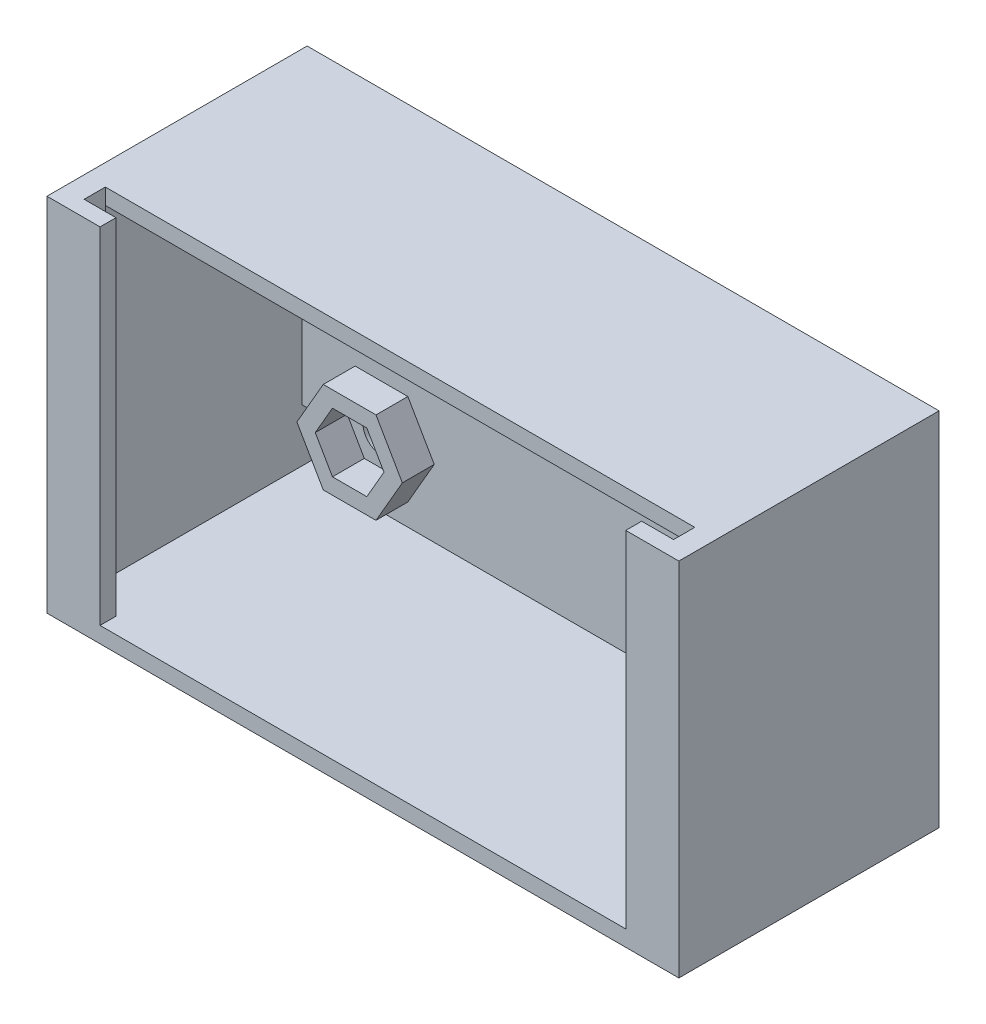
from build123d import *

# Parameters (mm, degrees)
CROQUIS1_W              = 59.5
CROQUIS1_H              = 34
CROQUIS1_W_2            = 56.5
CROQUIS1_H_2            = 31
EXTRUIR_L_MINA1_DEPTH   = 19
CROQUIS2_W              = 59.5
CROQUIS2_H              = 34
SALIENTE_EXTRUIR1_DEPTH = 2
SALIENTE_EXTRUIR3_DEPTH = 34
CROQUIS5_W              = 59.5
CROQUIS5_H              = 1.5
SALIENTE_EXTRUIR4_DEPTH = 3.5
CROQUIS6_W              = 5
CROQUIS6_H              = 5
CORTAR_EXTRUIR1_DEPTH   = 3.5
CROQUIS7_R              = 1.75
CORTAR_EXTRUIR2_DEPTH   = 3.5
EXTRUIR_L_MINA2_DEPTH   = 3


with BuildPart() as part:
    # Croquis1 → Extruir-Lámina1 (new body)
    with BuildSketch(Plane.XY):
        Rectangle(CROQUIS1_W, CROQUIS1_H)
        Rectangle(CROQUIS1_W_2, CROQUIS1_H_2, mode=Mode.SUBTRACT)
    extrude(amount=EXTRUIR_L_MINA1_DEPTH)

    # Croquis2 → Saliente-Extruir1 (add)
    with BuildSketch(Plane(origin=(0, 0, 0), x_dir=(-1, 0, 0), z_dir=(0, 0, -1))):
        Rectangle(CROQUIS2_W, CROQUIS2_H)
    extrude(amount=SALIENTE_EXTRUIR1_DEPTH)

    # Croquis4 → Saliente-Extruir3 (add)
    with BuildSketch(Plane(origin=(0, 17, 0), x_dir=(1, 0, 0), z_dir=(0, 1, 0))):
        Polygon((-29.75, -19), (-29.75, -22.5), (-24.75, -22.5), (-24.75, -21), (-27.75, -21), (-27.75, -19), align=None)
        Polygon((27.75, -21), (27.75, -19), (29.75, -19), (29.75, -22.5), (24.75, -22.5), (24.75, -21), align=None)
    extrude(amount=-SALIENTE_EXTRUIR3_DEPTH)

    # Croquis5 → Saliente-Extruir4 (add)
    with BuildSketch(Plane.XY.offset(19)):
        with Locations((0, -16.25)):
            Rectangle(CROQUIS5_W, CROQUIS5_H)
    extrude(amount=SALIENTE_EXTRUIR4_DEPTH)

    # Croquis6 → Cortar-Extruir1 (cut)
    with BuildSketch(Plane.XY):
        with Locations((-25.75, -13)):
            Rectangle(CROQUIS6_W, CROQUIS6_H)
    extrude(amount=-CORTAR_EXTRUIR1_DEPTH, mode=Mode.SUBTRACT)

    # Croquis7 → Cortar-Extruir2 (cut)
    with BuildSketch(Plane(origin=(0, 0, -2), x_dir=(-1, 0, 0), z_dir=(0, 0, -1))):
        with Locations((20.75, 12.11)):
            Circle(CROQUIS7_R)
        with Locations((20.75, -9.14)):
            Circle(CROQUIS7_R)
        with Locations((-24.25, -9.14)):
            Circle(CROQUIS7_R)
        with Locations((-24.25, 12.11)):
            Circle(CROQUIS7_R)
    extrude(amount=-CORTAR_EXTRUIR2_DEPTH, mode=Mode.SUBTRACT)

    # Croquis8 → Extruir-Lámina2 (add)
    with BuildSketch(Plane.XY):
        Polygon((-15.784787685, 12.11), (-18.267393842, 16.41), (-23.232606158, 16.41), (-25.715212315, 12.11), (-23.232606158, 7.81), (-18.267393842, 7.81), align=None)
        Polygon((-17.516838493, 12.11), (-19.133419246, 14.91), (-22.366580754, 14.91), (-23.983161507, 12.11), (-22.366580754, 9.31), (-19.133419246, 9.31), align=None, mode=Mode.SUBTRACT)
        Polygon((29.215212315, 12.11), (26.732606158, 16.41), (21.767393842, 16.41), (19.284787685, 12.11), (21.767393842, 7.81), (26.732606158, 7.81), align=None)
        Polygon((27.483161507, 12.11), (25.866580754, 14.91), (22.633419246, 14.91), (21.016838493, 12.11), (22.633419246, 9.31), (25.866580754, 9.31), align=None, mode=Mode.SUBTRACT)
        Polygon((-15.784787685, -9.14), (-18.267393842, -4.84), (-23.232606158, -4.84), (-25.715212315, -9.14), (-23.232606158, -13.44), (-18.267393842, -13.44), align=None)
        Polygon((-17.516838493, -9.14), (-19.133419246, -6.34), (-22.366580754, -6.34), (-23.983161507, -9.14), (-22.366580754, -11.94), (-19.133419246, -11.94), align=None, mode=Mode.SUBTRACT)
        Polygon((29.215212315, -9.14), (26.732606158, -4.84), (21.767393842, -4.84), (19.284787685, -9.14), (21.767393842, -13.44), (26.732606158, -13.44), align=None)
        Polygon((27.483161507, -9.14), (25.866580754, -6.34), (22.633419246, -6.34), (21.016838493, -9.14), (22.633419246, -11.94), (25.866580754, -11.94), align=None, mode=Mode.SUBTRACT)
    extrude(amount=EXTRUIR_L_MINA2_DEPTH)


solid = part.part
